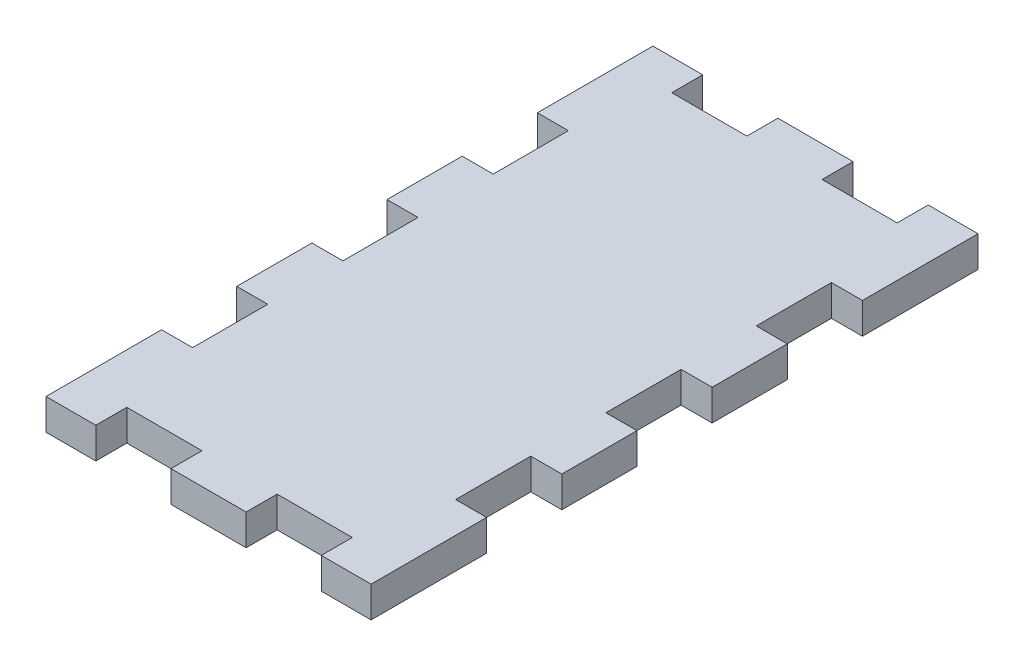
from build123d import *

# Parameters (mm, degrees)
ESQUISSE1_W             = 34.6
ESQUISSE1_H             = 64.6
BOSS_EXTRU_1_DEPTH      = 3.3
ENL_V_START             = -4.3
ESQUISSE2_W             = 8
ESQUISSE2_H             = 3.3
ENL_V_MAT_EXTRU_1_DEPTH = 5.3
ESQUISSE3_W             = 3.3
ESQUISSE3_H             = 8
ENL_V_MAT_EXTRU_2_DEPTH = 3.3


with BuildPart() as part:
    # Esquisse1 → Boss.-Extru.1 (new body)
    with BuildSketch(Plane(origin=(0, 0, 0), x_dir=(1, 0, 0), z_dir=(0, 1, 0))):
        Rectangle(ESQUISSE1_W, ESQUISSE1_H)
    extrude(amount=BOSS_EXTRU_1_DEPTH)

    # Esquisse2 → Enlèv. mat.-Extru.1 (cut)
    with BuildSketch(Plane(origin=(0, 3.3, 0), x_dir=(1, 0, 0), z_dir=(0, 1, 0)).offset(ENL_V_START)):
        with Locations((-8, 30.65)):
            Rectangle(ESQUISSE2_W, ESQUISSE2_H)
        with Locations((8, 30.65)):
            Rectangle(ESQUISSE2_W, ESQUISSE2_H)
    enl_v_mat_extru_1 = extrude(amount=ENL_V_MAT_EXTRU_1_DEPTH, mode=Mode.SUBTRACT)

    # Symétrie1: Enlèv. mat.-Extru.1 across plane
    add(enl_v_mat_extru_1.mirror(Plane.XY), mode=Mode.SUBTRACT)

    # Esquisse3 → Enlèv. mat.-Extru.2 (cut)
    with BuildSketch(Plane(origin=(0, 3.3, 0), x_dir=(1, 0, 0), z_dir=(0, 1, 0))):
        with Locations((-15.65, 0)):
            Rectangle(ESQUISSE3_W, ESQUISSE3_H)
        with Locations((-15.65, 16)):
            Rectangle(ESQUISSE3_W, ESQUISSE3_H)
        with Locations((-15.65, -16)):
            Rectangle(ESQUISSE3_W, ESQUISSE3_H)
    enl_v_mat_extru_2 = extrude(amount=-ENL_V_MAT_EXTRU_2_DEPTH, mode=Mode.SUBTRACT)

    # Symétrie2: Enlèv. mat.-Extru.2 across plane
    add(enl_v_mat_extru_2.mirror(Plane(origin=(0, 0, 0), x_dir=(0, 0, 1), z_dir=(1, 0, 0))), mode=Mode.SUBTRACT)


solid = part.part
